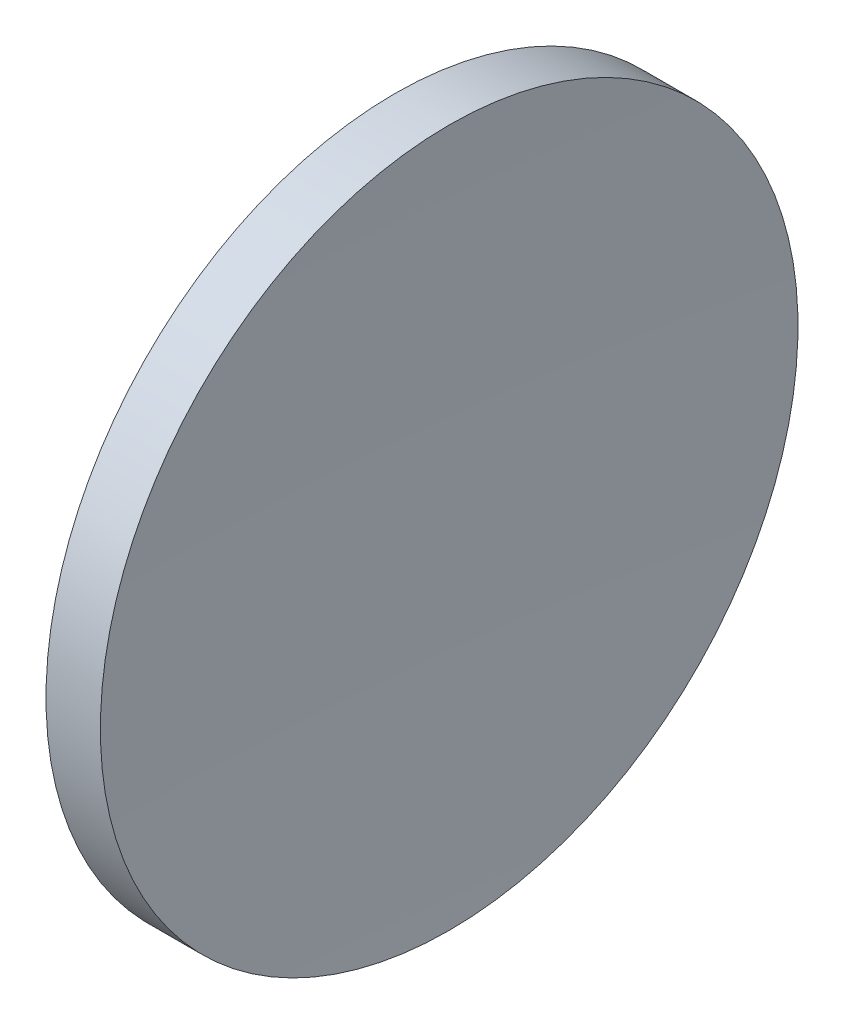
from build123d import *


with BuildPart() as part:
    # 草图1 → 旋转1 (revolve)
    with BuildSketch(Plane.XY):
        with BuildLine():
            Line((124.032024359, 84.241840471), (126.997062379, 84.241840471))
            ThreePointArc((126.997062379, 84.241840471), (126.665846452, 74.731903159), (126.555421316, 65.216840471))
            Line((126.555421316, 65.216840471), (122.855421316, 65.216840471))
            ThreePointArc((122.855421316, 65.216840471), (123.149852808, 74.747514893), (124.032024359, 84.241840471))
        make_face()
    revolve(axis=Axis((115.944491298, 65.216840471, 0), (1, 0, 0)))


solid = part.part
